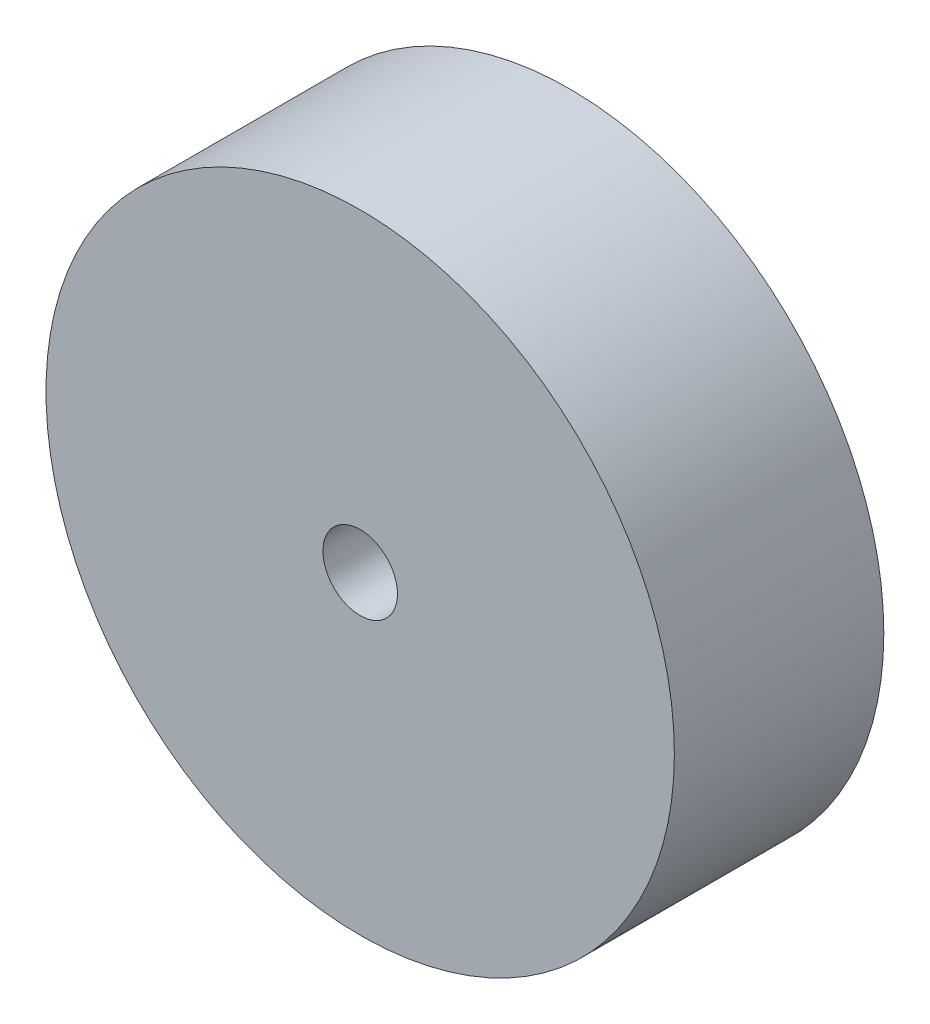
from build123d import *

# Parameters (mm, degrees)
SKETCH1_R             = 9.525
BOSS_EXTRUDE1_DEPTH   = 6.35
F_4_40_TAPPED_HOLE1_D = 2.2606


with BuildPart() as part:
    # Sketch1 → Boss-Extrude1 (new body)
    with BuildSketch(Plane.XY):
        Circle(SKETCH1_R)
    extrude(amount=BOSS_EXTRUDE1_DEPTH)

    # #4-40 Tapped Hole1 (through all)
    with Locations(Plane.XY.offset(6.35)):
        with Locations((0, 0)):
            Hole(F_4_40_TAPPED_HOLE1_D / 2)


solid = part.part
